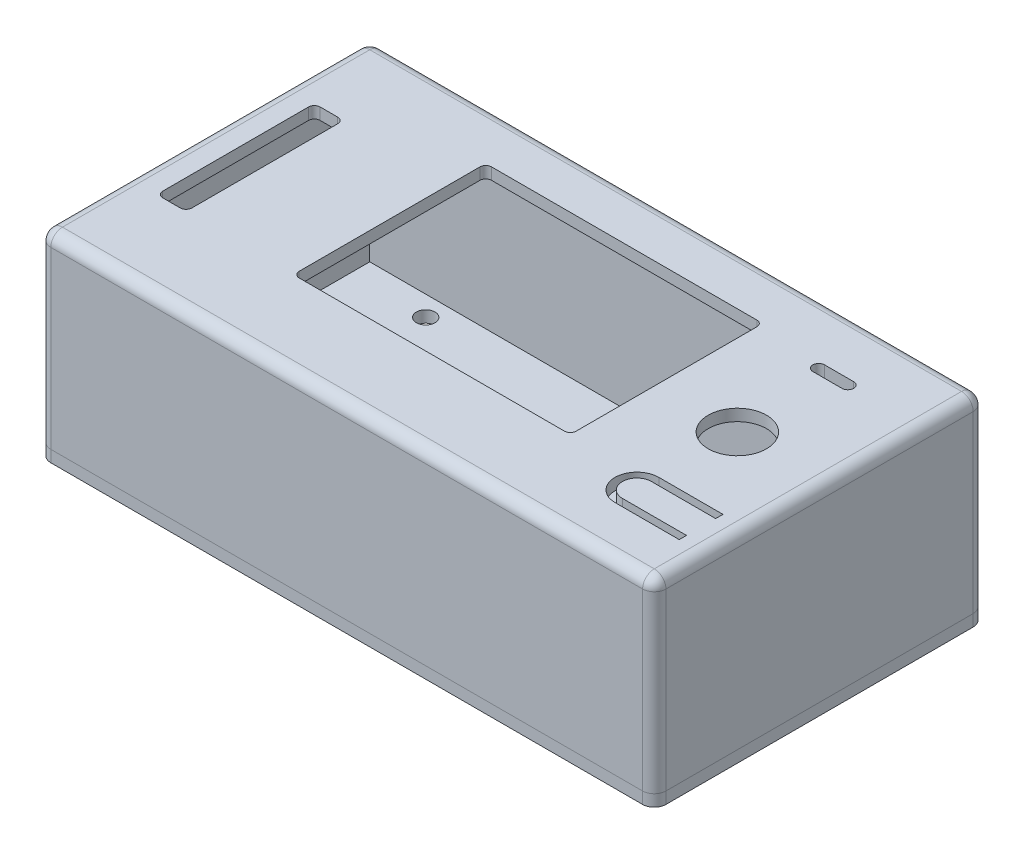
from build123d import *

# Parameters (mm, degrees)
CROQUIS1_W               = 105.5
CROQUIS1_H               = 56.7
CROQUIS1_R               = 5
CROQUIS1_W_2             = 47.5
CROQUIS1_H_2             = 33
CROQUIS1_W_3             = 5
CROQUIS1_H_3             = 27
SALIENTE_EXTRUIR1_DEPTH  = 2
CROQUIS5_W               = 105.5
CROQUIS5_H               = 56.7
CROQUIS5_W_2             = 102.5
CROQUIS5_H_2             = 53.7
SALIENTE_EXTRUIR4_DEPTH  = 30
CROQUIS6_W               = 105.5
CROQUIS6_H               = 56.7
CROQUIS6_R               = 1.6
SALIENTE_EXTRUIR5_DEPTH  = 2
CROQUIS8_W               = 6.15
CROQUIS8_H               = 7
SALIENTE_EXTRUIR13_DEPTH = 9
CROQUIS9_R               = 2.15
CORTAR_EXTRUIR2_DEPTH    = 3.5
REDONDEO4_R              = 2
REDONDEO6_R              = 1
REDONDEO7_R              = 1
CROQUIS10_R              = 2.5
SALIENTE_EXTRUIR14_DEPTH = 2


with BuildPart() as part:
    # Croquis1 → Saliente-Extruir1 (new body)
    with BuildSketch(Plane(origin=(0, 0, 0), x_dir=(1, 0, 0), z_dir=(0, 1, 0))):
        with Locations((50.5, 26.1)):
            Rectangle(CROQUIS1_W, CROQUIS1_H)
        with Locations((88.05, 27.2)):
            Circle(CROQUIS1_R, mode=Mode.SUBTRACT)
        with Locations((50.35, 29)):
            Rectangle(CROQUIS1_W_2, CROQUIS1_H_2, mode=Mode.SUBTRACT)
        with Locations((5.5, 26.2)):
            Rectangle(CROQUIS1_W_3, CROQUIS1_H_3, mode=Mode.SUBTRACT)
        with BuildLine():
            Line((88.05, 12.48), (99.05, 12.48))
            Line((99.05, 12.48), (99.05, 13.73))
            Line((99.05, 13.73), (88.05, 13.73))
            ThreePointArc((88.05, 13.73), (84.3, 9.98), (88.05, 6.23))
            Line((88.05, 6.23), (99.05, 6.23))
            Line((99.05, 6.23), (99.05, 7.48))
            Line((99.05, 7.48), (88.05, 7.48))
            ThreePointArc((88.05, 7.48), (85.55, 9.98), (88.05, 12.48))
        make_face(mode=Mode.SUBTRACT)
        with BuildLine():
            Line((90.55, 42.65), (85.55, 42.65))
            ThreePointArc((85.55, 42.65), (84.55, 43.65), (85.55, 44.65))
            Line((85.55, 44.65), (90.55, 44.65))
            ThreePointArc((90.55, 44.65), (91.55, 43.65), (90.55, 42.65))
        make_face(mode=Mode.SUBTRACT)
    extrude(amount=SALIENTE_EXTRUIR1_DEPTH)

    # Croquis5 → Saliente-Extruir4 (add)
    with BuildSketch(Plane.XZ):
        with Locations((50.5, -26.1)):
            Rectangle(CROQUIS5_W, CROQUIS5_H)
        with Locations((50.5, -26.1)):
            Rectangle(CROQUIS5_W_2, CROQUIS5_H_2, mode=Mode.SUBTRACT)
    extrude(amount=SALIENTE_EXTRUIR4_DEPTH)

    # Croquis6 → Saliente-Extruir5 (add)
    with BuildSketch(Plane.XZ.offset(30)):
        with Locations((50.5, -26.1)):
            Rectangle(CROQUIS6_W, CROQUIS6_H)
        with Locations((12.3, -49.5)):
            Circle(CROQUIS6_R, mode=Mode.SUBTRACT)
        with Locations((98.3, -2.7)):
            Circle(CROQUIS6_R, mode=Mode.SUBTRACT)
        with Locations((98.3, -49.5)):
            Circle(CROQUIS6_R, mode=Mode.SUBTRACT)
        with Locations((12.3, -2.7)):
            Circle(CROQUIS6_R, mode=Mode.SUBTRACT)
        with BuildLine():
            Line((40.75, -10.75), (19.75, -10.75))
            ThreePointArc((19.75, -10.75), (18.335786438, -10.164213562), (17.75, -8.75))
            Line((17.75, -8.75), (17.75, -2.75))
            ThreePointArc((17.75, -2.75), (18.335786438, -1.335786438), (19.75, -0.75))
            Line((19.75, -0.75), (40.75, -0.75))
            ThreePointArc((40.75, -0.75), (42.164213562, -1.335786438), (42.75, -2.75))
            Line((42.75, -2.75), (42.75, -8.75))
            ThreePointArc((42.75, -8.75), (42.164213562, -10.164213562), (40.75, -10.75))
        make_face(mode=Mode.SUBTRACT)
    extrude(amount=SALIENTE_EXTRUIR5_DEPTH)

    # Croquis8 → Saliente-Extruir13 (add)
    with BuildSketch(Plane.XZ):
        with Locations((12.3, -2.75)):
            Rectangle(CROQUIS8_W, CROQUIS8_H)
        with Locations((98.675, -2.75)):
            Rectangle(CROQUIS8_W, CROQUIS8_H)
        with Locations((12.3, -49.45)):
            Rectangle(CROQUIS8_W, CROQUIS8_H)
        with Locations((98.675, -49.45)):
            Rectangle(CROQUIS8_W, CROQUIS8_H)
    extrude(amount=SALIENTE_EXTRUIR13_DEPTH)

    # Croquis9 → Cortar-Extruir2 (cut)
    with BuildSketch(Plane.XZ.offset(9)):
        with Locations((12.3, -2.7)):
            Circle(CROQUIS9_R)
        with Locations((98.3, -2.7)):
            Circle(CROQUIS9_R)
        with Locations((98.3, -49.5)):
            Circle(CROQUIS9_R)
        with Locations((12.3, -49.5)):
            Circle(CROQUIS9_R)
    extrude(amount=-CORTAR_EXTRUIR2_DEPTH, mode=Mode.SUBTRACT)

    # Redondeo4
    redondeo4_edges = [part.edges().sort_by_distance(p)[0] for p in [
        (103.25, 2, -26.1),
        (50.5, 2, -54.45),
        (-2.25, 2, -26.1),
        (50.5, 2, 2.25),
        (-2.25, -15, -54.45),
        (103.25, -15, -54.45),
        (103.25, -15, 2.25),
        (-2.25, -15, 2.25),
    ]]
    fillet(redondeo4_edges, radius=REDONDEO4_R)


with BuildPart() as body_2:
    # Partir1: the piece on the far side of the plane
    add(part.part)
    split(bisect_by=Plane(origin=(0, -30, 0), x_dir=(0, 0, -1), z_dir=(0, -1, 0)), keep=Keep.BOTTOM)

    # Redondeo6
    redondeo6_edges = [body_2.edges().sort_by_distance(p)[0] for p in [
        (3, 1, -39.7),
        (8, 1, -39.7),
        (8, 1, -12.7),
        (3, 1, -12.7),
        (26.6, 1, -45.5),
        (74.1, 1, -45.5),
        (74.1, 1, -12.5),
        (26.6, 1, -12.5),
    ]]
    fillet(redondeo6_edges, radius=REDONDEO6_R)

    # Redondeo7
    redondeo7_edges = [body_2.edges().sort_by_distance(p)[0] for p in [
        (95.6, 0, -2.74),
        (100.4, 0, -6.25),
        (101.75, -4.5, -6.25),
        (95.6, -4.5, 0.75),
        (98.675, 0, -45.95),
        (95.6, 0, -49.45),
        (95.6, -4.5, -52.95),
        (101.75, -4.5, -45.95),
        (9.225, 0, -49.45),
        (15.375, 0, -49.45),
        (12.3, 0, -45.95),
        (15.375, -4.5, -52.95),
        (9.225, -4.5, -52.95),
        (9.225, 0, -2.75),
        (12.3, 0, -6.25),
        (15.375, 0, -2.75),
        (15.375, -4.5, 0.75),
        (9.225, -4.5, 0.75),
    ]]
    fillet(redondeo7_edges, radius=REDONDEO7_R)

    # Croquis10 → Saliente-Extruir14 (add)
    with BuildSketch(Plane.XZ):
        with Locations((88.05, -9.98)):
            Circle(CROQUIS10_R)
    extrude(amount=SALIENTE_EXTRUIR14_DEPTH)


with BuildPart() as part_1:
    add(part.part)

    # Partir1
    split(bisect_by=Plane(origin=(0, -30, 0), x_dir=(0, 0, -1), z_dir=(0, -1, 0)), keep=Keep.TOP)


solid = Compound([body_2.part, part_1.part])
